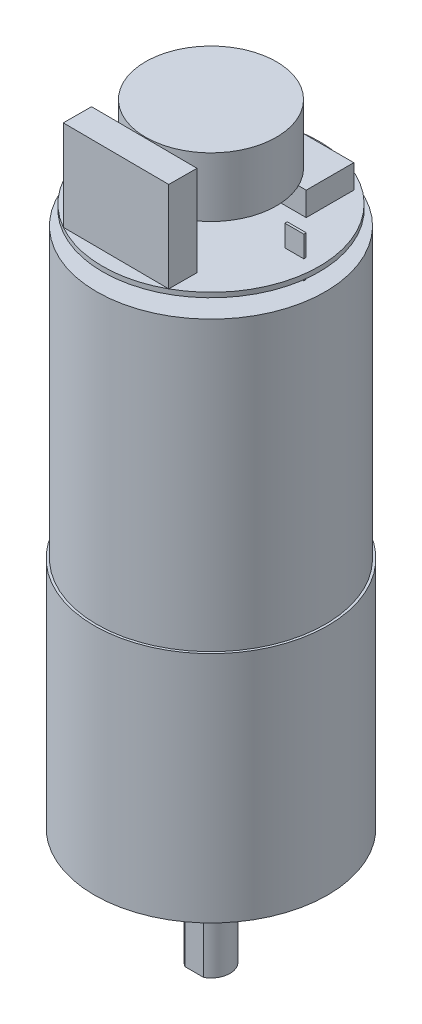
from build123d import *

# Parameters (mm, degrees)
SKETCH1_R                                       = 12.446
SKETCH1_R_2                                     = 1.27
BOSS_EXTRUDE1_DEPTH                             = 24.892
CSK_FOR_M3_FLAT_HEAD_MACHINE_SCREW1_D           = 3.4
CSK_FOR_M3_FLAT_HEAD_MACHINE_SCREW1_CSINK_D     = 6.3
CSK_FOR_M3_FLAT_HEAD_MACHINE_SCREW1_CSINK_ANGLE = 90
SKETCH5_R                                       = 12.192
BOSS_EXTRUDE2_DEPTH                             = 30.734
SKETCH6_R                                       = 3.556
BOSS_EXTRUDE3_DEPTH                             = 2.54
SKETCH7_R                                       = 2.032
BOSS_EXTRUDE4_DEPTH                             = 9.906
SKETCH8_W                                       = 2.032
SKETCH8_H                                       = 0.254
CUT_EXTRUDE2_DEPTH                              = 9.906
SKETCH9_R                                       = 3.175
BOSS_EXTRUDE5_DEPTH                             = 1.524
SKETCH10_W                                      = 2.032
SKETCH10_H                                      = 0.254
BOSS_EXTRUDE6_DEPTH                             = 4.318
SKETCH11_R                                      = 11.557
SKETCH11_W                                      = 2.032
SKETCH11_H                                      = 0.254
BOSS_EXTRUDE7_DEPTH                             = 0.508
SKETCH12_W                                      = 12.7
SKETCH12_H                                      = 5.08
BOSS_EXTRUDE8_DEPTH                             = 2.54
SKETCH13_W                                      = 3.81
SKETCH13_H                                      = 2.54
BOSS_EXTRUDE9_DEPTH                             = 2.794
BOSS_EXTRUDE10_DEPTH                            = 9.652
SKETCH15_R                                      = 3.175
BOSS_EXTRUDE11_DEPTH                            = 0.508
SKETCH16_R                                      = 6.985
BOSS_EXTRUDE12_DEPTH                            = 6.35


with BuildPart() as part:
    # Sketch1 → Boss-Extrude1 (new body)
    with BuildSketch(Plane(origin=(0, 0, 0), x_dir=(1, 0, 0), z_dir=(0, 1, 0))):
        Circle(SKETCH1_R)
        with Locations((-9.017, 0)):
            Circle(SKETCH1_R_2, mode=Mode.SUBTRACT)
        with Locations((9.017, 0)):
            Circle(SKETCH1_R_2, mode=Mode.SUBTRACT)
    extrude(amount=BOSS_EXTRUDE1_DEPTH)

    # CSK for M3 Flat Head Machine Screw1 (through all)
    with Locations(Plane(origin=(0, 24.892, 0), x_dir=(1, 0, 0), z_dir=(0, 1, 0))):
        with Locations((0, 8.119865968), (0, -7.587036194)):
            CounterSinkHole(CSK_FOR_M3_FLAT_HEAD_MACHINE_SCREW1_D / 2, CSK_FOR_M3_FLAT_HEAD_MACHINE_SCREW1_CSINK_D / 2, counter_sink_angle=CSK_FOR_M3_FLAT_HEAD_MACHINE_SCREW1_CSINK_ANGLE)

    # Sketch5 → Boss-Extrude2 (add)
    with BuildSketch(Plane(origin=(0, 24.892, 0), x_dir=(1, 0, 0), z_dir=(0, 1, 0))):
        Circle(SKETCH5_R)
    extrude(amount=BOSS_EXTRUDE2_DEPTH)

    # Sketch6 → Boss-Extrude3 (add)
    with BuildSketch(Plane(origin=(0, 0, 0), x_dir=(1, 0, 0), z_dir=(0, 1, 0))):
        Circle(SKETCH6_R)
    extrude(amount=-BOSS_EXTRUDE3_DEPTH)

    # Sketch7 → Boss-Extrude4 (add)
    with BuildSketch(Plane(origin=(0, -2.54, 0), x_dir=(-1, 0, 0), z_dir=(0, -1, 0))):
        Circle(SKETCH7_R)
    extrude(amount=BOSS_EXTRUDE4_DEPTH)

    # Sketch8 → Cut-Extrude2 (cut)
    with BuildSketch(Plane(origin=(0, -12.446, 0), x_dir=(-1, 0, 0), z_dir=(0, -1, 0))):
        with Locations((0, -1.905)):
            Rectangle(SKETCH8_W, SKETCH8_H)
        with Locations((0, 1.905)):
            Rectangle(SKETCH8_W, SKETCH8_H)
    extrude(amount=-CUT_EXTRUDE2_DEPTH, mode=Mode.SUBTRACT)

    # Sketch9 → Boss-Extrude5 (add)
    with BuildSketch(Plane(origin=(0, 55.626, 0), x_dir=(1, 0, 0), z_dir=(0, 1, 0))):
        Circle(SKETCH9_R)
    extrude(amount=BOSS_EXTRUDE5_DEPTH)

    # Sketch10 → Boss-Extrude6 (add)
    with BuildSketch(Plane(origin=(0, 55.626, 0), x_dir=(1, 0, 0), z_dir=(0, 1, 0))):
        with Locations((-9.017, 0)):
            Rectangle(SKETCH10_W, SKETCH10_H)
        with Locations((9.017, 0)):
            Rectangle(SKETCH10_W, SKETCH10_H)
    extrude(amount=BOSS_EXTRUDE6_DEPTH)

    # Sketch11 → Boss-Extrude7 (add)
    with BuildSketch(Plane(origin=(0, 57.15, 0), x_dir=(1, 0, 0), z_dir=(0, 1, 0))):
        Circle(SKETCH11_R)
        with Locations((-9.017, 0)):
            Rectangle(SKETCH11_W, SKETCH11_H, mode=Mode.SUBTRACT)
        with Locations((9.017, 0)):
            Rectangle(SKETCH11_W, SKETCH11_H, mode=Mode.SUBTRACT)
    extrude(amount=BOSS_EXTRUDE7_DEPTH)

    # Sketch12 → Boss-Extrude8 (add)
    with BuildSketch(Plane(origin=(0, 57.658, 0), x_dir=(1, 0, 0), z_dir=(0, 1, 0))):
        with Locations((0, 6.35)):
            Rectangle(SKETCH12_W, SKETCH12_H)
    extrude(amount=BOSS_EXTRUDE8_DEPTH)

    # Sketch13 → Boss-Extrude9 (add)
    with BuildSketch(Plane(origin=(0, 57.658, 0), x_dir=(1, 0, 0), z_dir=(0, 1, 0))):
        Rectangle(SKETCH13_W, SKETCH13_H)
    extrude(amount=BOSS_EXTRUDE9_DEPTH)

    # Sketch14 → Boss-Extrude10 (add)
    with BuildSketch(Plane(origin=(0, 57.658, 0), x_dir=(1, 0, 0), z_dir=(0, 1, 0))):
        Polygon((-5.718475067, -10.043071836), (5.597401443, -10.111050692), (5.615425354, -7.110759652), (-5.700451156, -7.042780797), align=None)
    extrude(amount=BOSS_EXTRUDE10_DEPTH)

    # Sketch15 → Boss-Extrude11 (add)
    with BuildSketch(Plane(origin=(0, 60.452, 0), x_dir=(1, 0, 0), z_dir=(0, 1, 0))):
        Circle(SKETCH15_R)
    extrude(amount=BOSS_EXTRUDE11_DEPTH)

    # Sketch16 → Boss-Extrude12 (add)
    with BuildSketch(Plane(origin=(0, 60.96, 0), x_dir=(1, 0, 0), z_dir=(0, 1, 0))):
        Circle(SKETCH16_R)
    extrude(amount=BOSS_EXTRUDE12_DEPTH)


solid = part.part
